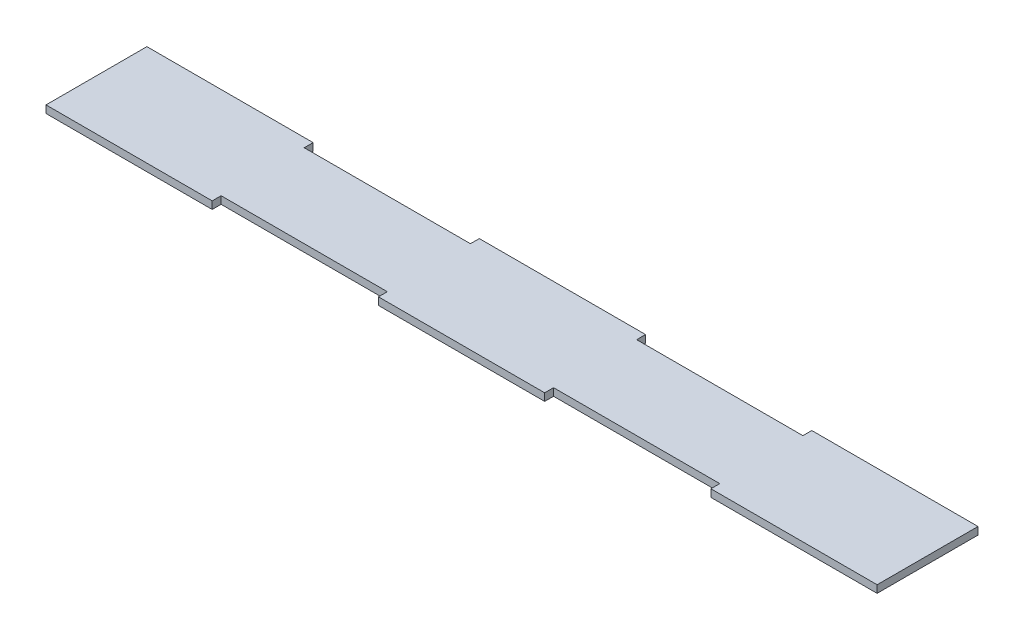
from build123d import *

# Parameters (mm, degrees)
BOSS_EXTRUDE1_DEPTH = 2.7


with BuildPart() as part:
    # Sketch1 → Boss-Extrude1 (new body)
    with BuildSketch(Plane(origin=(0, 0, 0), x_dir=(1, 0, 0), z_dir=(0, 1, 0))):
        Polygon((30, 15), (90, 15), (90, 18.21), (150, 18.21), (150, -18.21), (90, -18.21), (90, -15), (30, -15), (30, -18.21), (-30, -18.21), (-30, -15), (-90, -15), (-90, -18.21), (-150, -18.21), (-150, 18.21), (-90, 18.21), (-90, 15), (-30, 15), (-30, 18.21), (30, 18.21), align=None)
    extrude(amount=BOSS_EXTRUDE1_DEPTH)


solid = part.part
